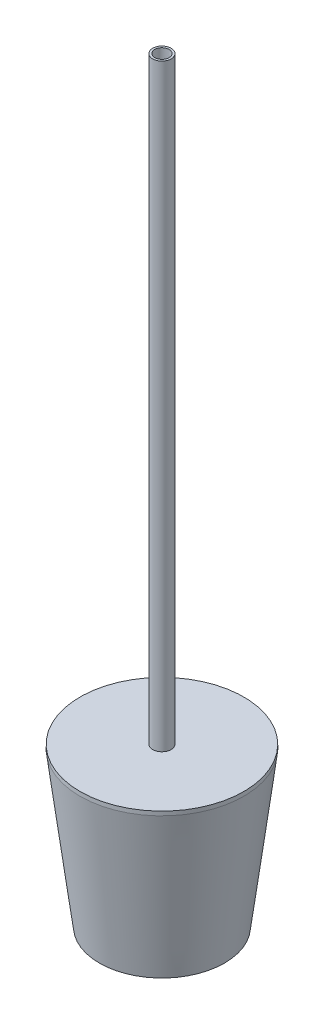
from build123d import *

# Parameters (mm, degrees)
SKETCH3_R                = 450.388011064
SKETCH3_R_2              = 50.774314147
BOSS_EXTRUDE1_DEPTH      = 22.606
SKETCH4_R                = 50.8
SKETCH4_R_2              = 39.37
BOSS_EXTRUDE2_DEPTH      = 3311.652
BOSS_EXTRUDE2_DEPTH_BACK = 330.2


with BuildPart() as part:
    # Sketch2 → Revolve1 (revolve)
    with BuildSketch(Plane.XY):
        Polygon((0, 0), (0, -50.000000076), (344.139110806, -50.000000076), (450.388011064, 799.991191009), (400.000001233, 799.999999946), (299.999999948, 0), align=None)
    revolve(axis=Axis((0, -50.000000076, 0), (0, 1, 0)))

    # Sketch3 → Boss-Extrude1 (add)
    with BuildSketch(Plane(origin=(0, 797.56, 0), x_dir=(1, 0, 0), z_dir=(0, 1, 0))):
        Circle(SKETCH3_R)
        Circle(SKETCH3_R_2, mode=Mode.SUBTRACT)
    extrude(amount=BOSS_EXTRUDE1_DEPTH)

    # Sketch4 → Boss-Extrude2 (add, two sides)
    with BuildSketch(Plane(origin=(0, 797.56, 0), x_dir=(1, 0, 0), z_dir=(0, 1, 0))) as boss_extrude2_sk:
        Circle(SKETCH4_R)
        Circle(SKETCH4_R_2, mode=Mode.SUBTRACT)
    extrude(amount=BOSS_EXTRUDE2_DEPTH)
    extrude(boss_extrude2_sk.sketch, amount=-BOSS_EXTRUDE2_DEPTH_BACK)


solid = part.part
